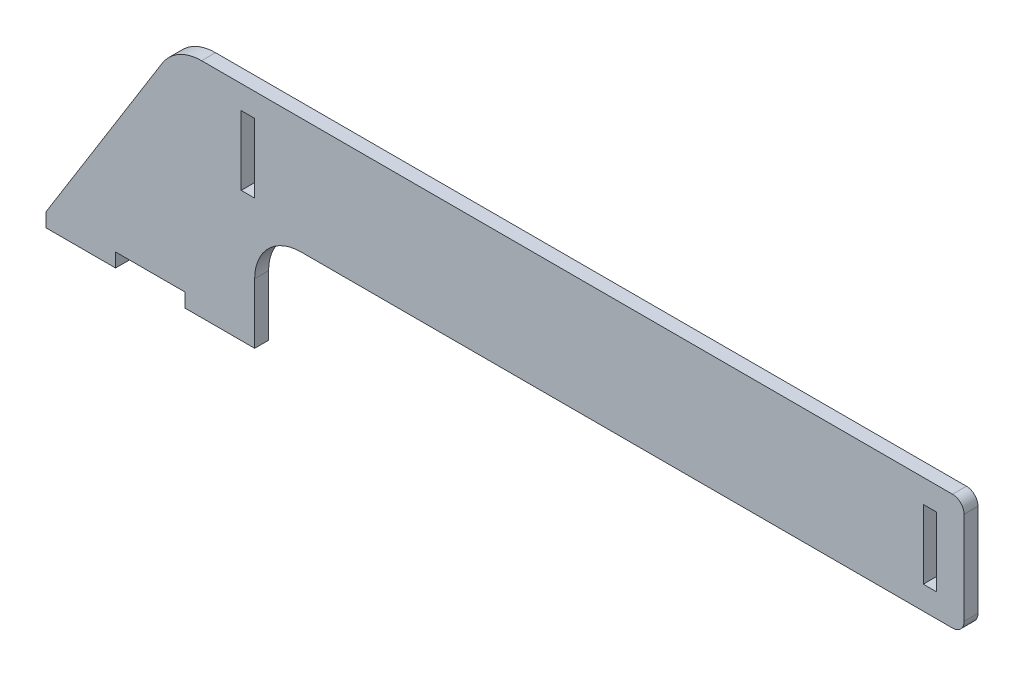
from build123d import *

# Parameters (mm, degrees)
SALIENTE_EXTRUIR1_DEPTH = 6
CROQUIS2_W              = 30
CROQUIS2_H              = 6
SALIENTE_EXTRUIR2_DEPTH = 6
CORTAR_EXTRUIR1_REACH   = 8
CROQUIS3_W              = 5.8
CROQUIS3_H              = 29.8
REDONDEO1_R             = 20
REDONDEO2_R             = 5


with BuildPart() as part:
    # Croquis1 → Saliente-Extruir1 (new body)
    with BuildSketch(Plane.XY):
        Polygon((-90, -40), (-34, 50), (306, 50), (306, 0), (0, 0), (0, -40), align=None)
    extrude(amount=SALIENTE_EXTRUIR1_DEPTH)

    # Croquis2 → Saliente-Extruir2 (add)
    with BuildSketch(Plane.XZ.offset(40)):
        with Locations((-75, 3)):
            Rectangle(CROQUIS2_W, CROQUIS2_H)
        with Locations((-15, 3)):
            Rectangle(CROQUIS2_W, CROQUIS2_H)
    extrude(amount=SALIENTE_EXTRUIR2_DEPTH)

    # Croquis3 → Cortar-Extruir1 (cut, up to next)
    with BuildSketch(Plane.XY.offset(6), mode=Mode.PRIVATE) as cortar_extruir1_sk1:
        with Locations((-2.9, 25)):
            Rectangle(CROQUIS3_W, CROQUIS3_H)
    cortar_extruir1_tool1 = extrude(cortar_extruir1_sk1.sketch, amount=-CORTAR_EXTRUIR1_REACH, mode=Mode.PRIVATE) & part.part
    add(cortar_extruir1_tool1.solids().sort_by_distance((-2.9, 25, 6))[0], mode=Mode.SUBTRACT)
    # Croquis3 → Cortar-Extruir1 (cut, up to next)
    with BuildSketch(Plane.XY.offset(6), mode=Mode.PRIVATE) as cortar_extruir1_sk2:
        with Locations((291.3, 25)):
            Rectangle(CROQUIS3_W, CROQUIS3_H)
    cortar_extruir1_tool2 = extrude(cortar_extruir1_sk2.sketch, amount=-CORTAR_EXTRUIR1_REACH, mode=Mode.PRIVATE) & part.part
    add(cortar_extruir1_tool2.solids().sort_by_distance((291.3, 25, 6))[0], mode=Mode.SUBTRACT)

    # Redondeo1
    redondeo1_edges = [part.edges().sort_by_distance(p)[0] for p in [
        (-34, 50, 3),
        (0, 0, 3),
    ]]
    fillet(redondeo1_edges, radius=REDONDEO1_R)

    # Redondeo2
    redondeo2_edges = [part.edges().sort_by_distance(p)[0] for p in [
        (306, 50, 3),
        (306, 0, 3),
    ]]
    fillet(redondeo2_edges, radius=REDONDEO2_R)


solid = part.part
